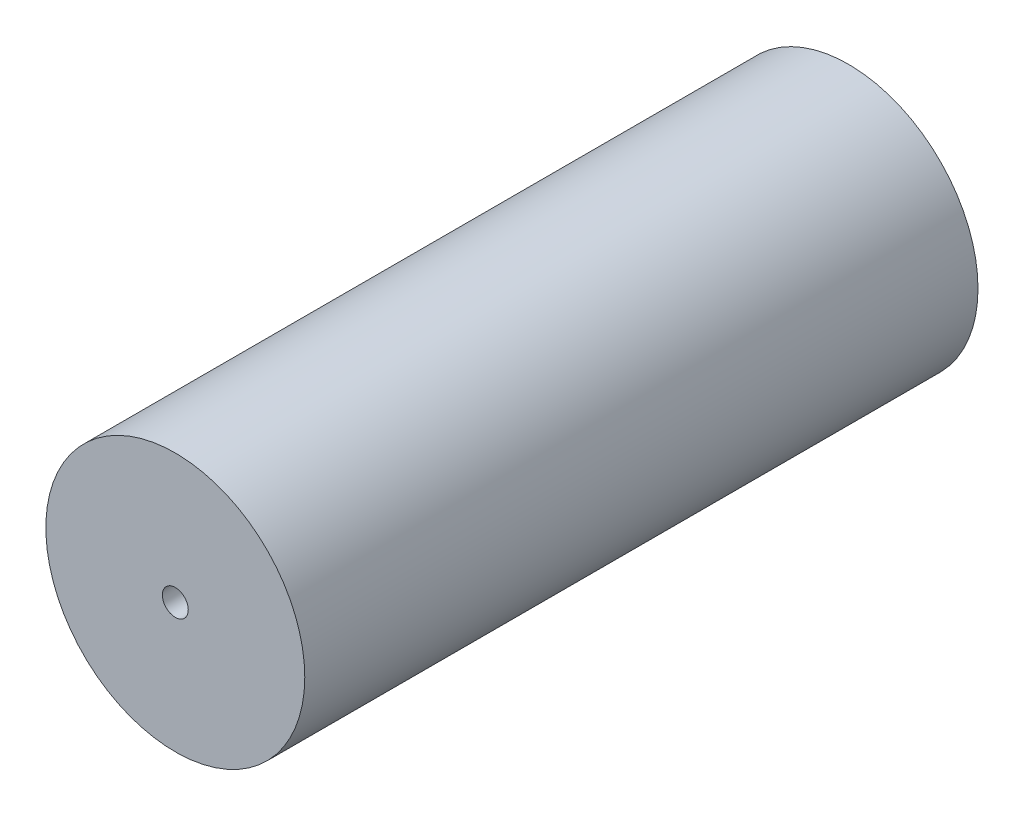
from build123d import *

# Parameters (mm, degrees)
SKETCH1_R           = 5
SKETCH1_R_2         = 0.5
BOSS_EXTRUDE1_DEPTH = 26


with BuildPart() as part:
    # Sketch1 → Boss-Extrude1 (new body)
    with BuildSketch(Plane.XY):
        Circle(SKETCH1_R)
        Circle(SKETCH1_R_2, mode=Mode.SUBTRACT)
    extrude(amount=BOSS_EXTRUDE1_DEPTH)


solid = part.part
